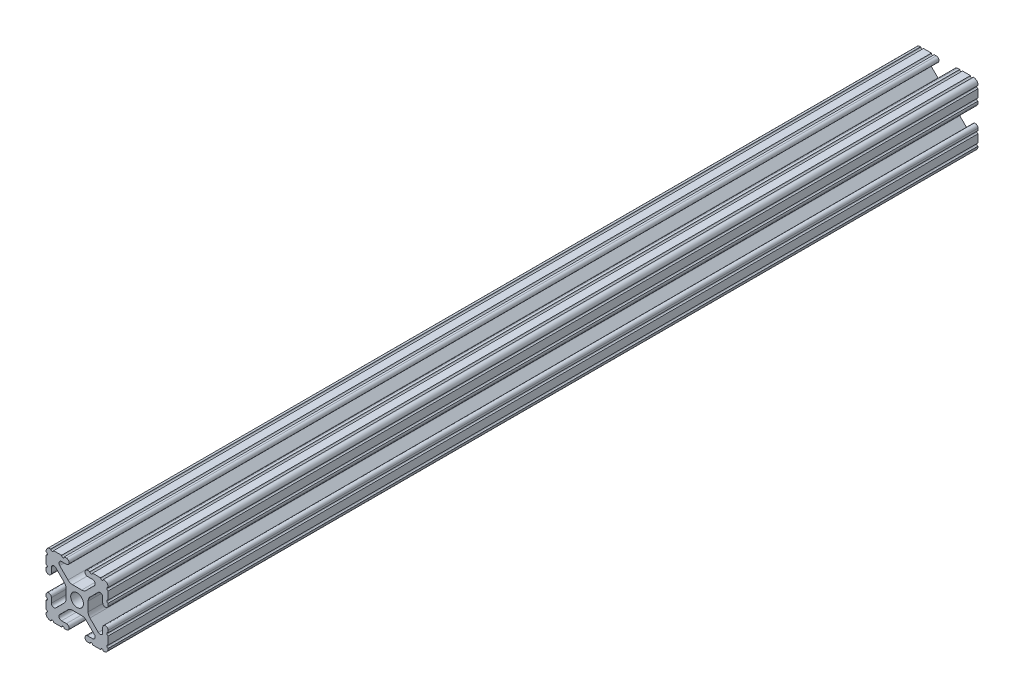
from build123d import *

# Parameters (mm, degrees)
SKETCH3_W                = 25.4
SKETCH3_H                = 25.4
BOSS_EXTRUDE1_DEPTH      = 177.8
BOSS_EXTRUDE1_DEPTH_BACK = 177.8
SKETCH4_R                = 2.6035
CUT_EXTRUDE1_DEPTH       = 356.6
CUT_EXTRUDE2_DEPTH       = 356.6
FILLET1_R                = 2.54
FILLET2_R                = 1.778


with BuildPart() as part:
    # Sketch3 → Boss-Extrude1 (new body, two sides)
    with BuildSketch(Plane.XY) as boss_extrude1_sk:
        Rectangle(SKETCH3_W, SKETCH3_H)
    extrude(amount=BOSS_EXTRUDE1_DEPTH)
    extrude(boss_extrude1_sk.sketch, amount=-BOSS_EXTRUDE1_DEPTH_BACK)

    # Sketch4 → Cut-Extrude1 (cut, through all)
    with BuildSketch(Plane.XY.offset(177.8)):
        with BuildLine():
            Line((3.2512, 12.7), (-3.2512, 12.7))
            Line((-3.2512, 12.7), (-3.2512, 10.4902))
            Line((-3.2512, 10.4902), (-6.348478019, 10.4902))
            ThreePointArc((-6.348478019, 10.4902), (-7.335478831, 9.830707141), (-7.103895736, 8.666460301))
            Line((-7.103895736, 8.666460301), (-2.958635435, 4.5212))
            Line((-2.958635435, 4.5212), (2.958635435, 4.5212))
            Line((2.958635435, 4.5212), (7.103895736, 8.666460301))
            ThreePointArc((7.103895736, 8.666460301), (7.335478831, 9.830707141), (6.348478019, 10.4902))
            Line((6.348478019, 10.4902), (3.2512, 10.4902))
            Line((3.2512, 10.4902), (3.2512, 12.7))
        make_face()
        with BuildLine():
            Line((12.7, -3.2512), (12.7, 3.2512))
            Line((12.7, 3.2512), (10.4902, 3.2512))
            Line((10.4902, 3.2512), (10.4902, 6.348478019))
            ThreePointArc((10.4902, 6.348478019), (9.830707141, 7.335478831), (8.666460301, 7.103895736))
            Line((8.666460301, 7.103895736), (4.5212, 2.958635435))
            Line((4.5212, 2.958635435), (4.5212, -2.958635435))
            Line((4.5212, -2.958635435), (8.666460301, -7.103895736))
            ThreePointArc((8.666460301, -7.103895736), (9.830707141, -7.335478831), (10.4902, -6.348478019))
            Line((10.4902, -6.348478019), (10.4902, -3.2512))
            Line((10.4902, -3.2512), (12.7, -3.2512))
        make_face()
        with BuildLine():
            Line((-3.2512, -10.4902), (-3.2512, -12.7))
            Line((-3.2512, -12.7), (3.2512, -12.7))
            Line((3.2512, -12.7), (3.2512, -10.4902))
            Line((3.2512, -10.4902), (6.348478019, -10.4902))
            ThreePointArc((6.348478019, -10.4902), (7.335478831, -9.830707141), (7.103895736, -8.666460301))
            Line((7.103895736, -8.666460301), (2.958635435, -4.5212))
            Line((2.958635435, -4.5212), (-2.958635435, -4.5212))
            Line((-2.958635435, -4.5212), (-7.103895736, -8.666460301))
            ThreePointArc((-7.103895736, -8.666460301), (-7.335478831, -9.830707141), (-6.348478019, -10.4902))
            Line((-6.348478019, -10.4902), (-3.2512, -10.4902))
        make_face()
        with BuildLine():
            Line((-10.4902, 3.2512), (-12.7, 3.2512))
            Line((-12.7, 3.2512), (-12.7, -3.2512))
            Line((-12.7, -3.2512), (-10.4902, -3.2512))
            Line((-10.4902, -3.2512), (-10.4902, -6.348478019))
            ThreePointArc((-10.4902, -6.348478019), (-9.830707141, -7.335478831), (-8.666460301, -7.103895736))
            Line((-8.666460301, -7.103895736), (-4.5212, -2.958635435))
            Line((-4.5212, -2.958635435), (-4.5212, 2.958635435))
            Line((-4.5212, 2.958635435), (-8.666460301, 7.103895736))
            ThreePointArc((-8.666460301, 7.103895736), (-9.830707141, 7.335478831), (-10.4902, 6.348478019))
            Line((-10.4902, 6.348478019), (-10.4902, 3.2512))
        make_face()
        Circle(SKETCH4_R)
    extrude(amount=-CUT_EXTRUDE1_DEPTH, mode=Mode.SUBTRACT)

    # Sketch5 → Cut-Extrude2 (cut, through all)
    with BuildSketch(Plane.XY.offset(177.8)):
        with BuildLine():
            ThreePointArc((-11.5951, 3.2512), (-12.376382283, 3.574817717), (-12.7, 4.3561))
            Line((-12.7, 4.3561), (-12.7, 3.2512))
            Line((-12.7, 3.2512), (-11.5951, 3.2512))
        make_face()
        with BuildLine():
            ThreePointArc((-10.4902, 4.3561), (-10.813817717, 3.574817717), (-11.5951, 3.2512))
            Line((-11.5951, 3.2512), (-10.4902, 3.2512))
            Line((-10.4902, 3.2512), (-10.4902, 4.3561))
        make_face()
        with BuildLine():
            Line((-12.7, -3.2512), (-12.7, -4.3561))
            ThreePointArc((-12.7, -4.3561), (-12.376382283, -3.574817717), (-11.5951, -3.2512))
            Line((-11.5951, -3.2512), (-12.7, -3.2512))
        make_face()
        with BuildLine():
            Line((-10.4902, -3.2512), (-11.5951, -3.2512))
            ThreePointArc((-11.5951, -3.2512), (-10.813817717, -3.574817717), (-10.4902, -4.3561))
            Line((-10.4902, -4.3561), (-10.4902, -3.2512))
        make_face()
        with BuildLine():
            Line((-3.2512, -11.595100007), (-3.2512, -10.4902))
            Line((-3.2512, -10.4902), (-4.3561, -10.4902))
            ThreePointArc((-4.3561, -10.4902), (-3.574817715, -10.81381772), (-3.2512, -11.595100007))
        make_face()
        with BuildLine():
            Line((-3.2512, -12.7), (-3.2512, -11.595100007))
            ThreePointArc((-3.2512, -11.595100007), (-3.57481772, -12.376382285), (-4.3561, -12.7))
            Line((-4.3561, -12.7), (-3.2512, -12.7))
        make_face()
        with BuildLine():
            Line((3.2512, -10.4902), (3.2512, -11.5951))
            ThreePointArc((3.2512, -11.5951), (3.574817718, -10.813817717), (4.3561, -10.4902))
            Line((4.3561, -10.4902), (3.2512, -10.4902))
        make_face()
        with BuildLine():
            Line((3.2512, -12.7), (4.3561, -12.7))
            ThreePointArc((4.3561, -12.7), (3.574817717, -12.376382282), (3.2512, -11.5951))
            Line((3.2512, -11.5951), (3.2512, -12.7))
        make_face()
        with BuildLine():
            Line((11.5951, -3.2512), (10.4902, -3.2512))
            Line((10.4902, -3.2512), (10.4902, -4.3561))
            ThreePointArc((10.4902, -4.3561), (10.813817717, -3.574817717), (11.5951, -3.2512))
        make_face()
        with BuildLine():
            Line((12.7, -3.2512), (11.5951, -3.2512))
            ThreePointArc((11.5951, -3.2512), (12.376382283, -3.574817717), (12.7, -4.3561))
            Line((12.7, -4.3561), (12.7, -3.2512))
        make_face()
        with BuildLine():
            Line((10.4902, 3.2512), (11.5951, 3.2512))
            ThreePointArc((11.5951, 3.2512), (10.813817717, 3.574817717), (10.4902, 4.3561))
            Line((10.4902, 4.3561), (10.4902, 3.2512))
        make_face()
        with BuildLine():
            Line((12.7, 3.2512), (12.7, 4.3561))
            ThreePointArc((12.7, 4.3561), (12.376382283, 3.574817717), (11.5951, 3.2512))
            Line((11.5951, 3.2512), (12.7, 3.2512))
        make_face()
        with BuildLine():
            Line((3.2512, 12.7), (3.2512, 11.595099996))
            ThreePointArc((3.2512, 11.595099996), (3.574817716, 12.376382281), (4.3561, 12.7))
            Line((4.3561, 12.7), (3.2512, 12.7))
        make_face()
        with BuildLine():
            Line((3.2512, 11.595099996), (3.2512, 10.4902))
            Line((3.2512, 10.4902), (4.3561, 10.4902))
            ThreePointArc((4.3561, 10.4902), (3.574817719, 10.813817716), (3.2512, 11.595099996))
        make_face()
        with BuildLine():
            Line((-3.2512, 12.7), (-4.3561, 12.7))
            ThreePointArc((-4.3561, 12.7), (-3.574817717, 12.376382283), (-3.2512, 11.5951))
            Line((-3.2512, 11.5951), (-3.2512, 12.7))
        make_face()
        with BuildLine():
            Line((-3.2512, 10.4902), (-3.2512, 11.5951))
            ThreePointArc((-3.2512, 11.5951), (-3.574817717, 10.813817717), (-4.3561, 10.4902))
            Line((-4.3561, 10.4902), (-3.2512, 10.4902))
        make_face()
        with BuildLine():
            ThreePointArc((-12.7, 5.23875), (-12.14755, 5.7912), (-12.7, 6.34365))
            Line((-12.7, 6.34365), (-12.7, 5.23875))
        make_face()
        with BuildLine():
            ThreePointArc((-12.7, 9.60755), (-12.14755, 10.16), (-12.7, 10.71245))
            Line((-12.7, 10.71245), (-12.7, 9.60755))
        make_face()
        with BuildLine():
            ThreePointArc((-10.71245, 12.7), (-10.16, 12.14755), (-9.60755, 12.7))
            Line((-9.60755, 12.7), (-10.71245, 12.7))
        make_face()
        with BuildLine():
            ThreePointArc((-6.34365, 12.7), (-5.7912, 12.14755), (-5.23875, 12.7))
            Line((-5.23875, 12.7), (-6.34365, 12.7))
        make_face()
        with BuildLine():
            Line((6.34365, 12.7), (5.23875, 12.7))
            ThreePointArc((5.23875, 12.7), (5.7912, 12.14755), (6.34365, 12.7))
        make_face()
        with BuildLine():
            Line((10.71245, 12.7), (9.60755, 12.7))
            ThreePointArc((9.60755, 12.7), (10.16, 12.14755), (10.71245, 12.7))
        make_face()
        with BuildLine():
            Line((12.7, 10.71245), (12.7, 9.60755))
            ThreePointArc((12.7, 9.60755), (12.14755, 10.16), (12.7, 10.71245))
        make_face()
        with BuildLine():
            Line((12.7, 6.34365), (12.7, 5.23875))
            ThreePointArc((12.7, 5.23875), (12.14755, 5.7912), (12.7, 6.34365))
        make_face()
        with BuildLine():
            Line((-12.7, -6.34365), (-12.7, -5.23875))
            ThreePointArc((-12.7, -5.23875), (-12.14755, -5.7912), (-12.7, -6.34365))
        make_face()
        with BuildLine():
            Line((-12.7, -10.71245), (-12.7, -9.60755))
            ThreePointArc((-12.7, -9.60755), (-12.14755, -10.16), (-12.7, -10.71245))
        make_face()
        with BuildLine():
            Line((-10.71245, -12.7), (-9.60755, -12.7))
            ThreePointArc((-9.60755, -12.7), (-10.16, -12.14755), (-10.71245, -12.7))
        make_face()
        with BuildLine():
            Line((-6.34365, -12.7), (-5.23875, -12.7))
            ThreePointArc((-5.23875, -12.7), (-5.7912, -12.14755), (-6.34365, -12.7))
        make_face()
        with BuildLine():
            Line((12.7, -10.71245), (12.7, -9.60755))
            ThreePointArc((12.7, -9.60755), (12.14755, -10.16), (12.7, -10.71245))
        make_face()
        with BuildLine():
            Line((12.7, -6.34365), (12.7, -5.23875))
            ThreePointArc((12.7, -5.23875), (12.14755, -5.7912), (12.7, -6.34365))
        make_face()
        with BuildLine():
            Line((10.71245, -12.7), (9.60755, -12.7))
            ThreePointArc((9.60755, -12.7), (10.16, -12.14755), (10.71245, -12.7))
        make_face()
        with BuildLine():
            Line((6.34365, -12.7), (5.23875, -12.7))
            ThreePointArc((5.23875, -12.7), (5.7912, -12.14755), (6.34365, -12.7))
        make_face()
    extrude(amount=-CUT_EXTRUDE2_DEPTH, mode=Mode.SUBTRACT)

    # Fillet1
    fillet1_edges = [part.edges().sort_by_distance(p)[0] for p in [
        (2.958635435, 4.5212, 0),
        (-2.958635435, 4.5212, 0),
        (-2.958635435, -4.5212, 0),
        (2.958635435, -4.5212, 0),
        (4.5212, -2.958635435, 0),
        (4.5212, 2.958635435, 0),
        (-4.5212, 2.958635435, 0),
        (-4.5212, -2.958635435, 0),
    ]]
    fillet(fillet1_edges, radius=FILLET1_R)

    # Fillet2
    fillet2_edges = [part.edges().sort_by_distance(p)[0] for p in [
        (-12.7, 12.7, 0),
        (12.7, 12.7, 0),
        (12.7, -12.7, 0),
        (-12.7, -12.7, 0),
    ]]
    fillet(fillet2_edges, radius=FILLET2_R)


solid = part.part
